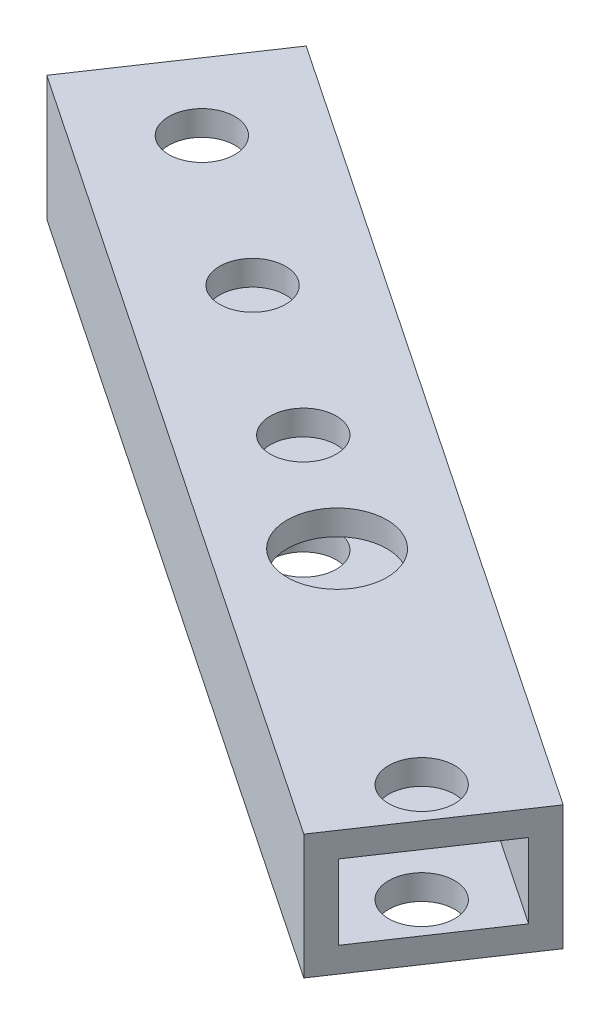
from build123d import *

# Parameters (mm, degrees)
SKETCH_1_R               = 275
SKETCH_1_R_2             = 255
EXTRUDE_1_DEPTH          = 10
EXTRUDE_2_DEPTH          = 10
SKETCH_8_R               = 2.65
SKETCH_8_R_2             = 1.65
SKETCH_8_R_3             = 2.15
CUT_EXTRUDE_1_DEPTH      = 21
SKETCH_9_OUTSIDE_W       = 707.614
SKETCH_9_OUTSIDE_H       = 707.614
CUT_EXTRUDE_2_DEPTH      = 21
EXTRUDE_3_DEPTH          = 10
SKETCH_11_W              = 11
SKETCH_11_H              = 6
CUT_EXTRUDE_3_DEPTH      = 509.636319812
CUT_EXTRUDE_3_DEPTH_BACK = 255.723154156
SKETCH_12_W              = 684.820669576
SKETCH_12_H              = 20
CUT_EXTRUDE_4_DEPTH      = 230.939436413
CUT_EXTRUDE_4_DEPTH_BACK = 534.420037555
SKETCH_14_R              = 4
CUT_EXTRUDE_6_DEPTH      = 11


with BuildPart() as part:
    # 草图1 → 凸台-拉伸1 (new body)
    with BuildSketch(Plane(origin=(0, 0, 0), x_dir=(1, 0, 0), z_dir=(0, 1, 0))):
        Circle(SKETCH_1_R)
        Circle(SKETCH_1_R_2, mode=Mode.SUBTRACT)
    extrude(amount=EXTRUDE_1_DEPTH)

    # 草图12 → 切除-拉伸4 (cut, two sides)
    with BuildSketch(Plane(origin=(84.710658728, 0, -125.893697679), x_dir=(-0.829665535, 0, -0.558260781), z_dir=(0.558260781, 0, -0.829665535))) as cut_extrude_4_sk:
        Rectangle(SKETCH_12_W, SKETCH_12_H)
    extrude(amount=CUT_EXTRUDE_4_DEPTH, mode=Mode.SUBTRACT)
    extrude(cut_extrude_4_sk.sketch, amount=-CUT_EXTRUDE_4_DEPTH_BACK, mode=Mode.SUBTRACT)


with BuildPart() as body_2:
    # 草图2 → 凸台-拉伸2 (new body)
    with BuildSketch(Plane(origin=(0, 10, 0), x_dir=(1, 0, 0), z_dir=(0, 1, 0))):
        with BuildLine():
            Line((-110.525139894, 257.262887824), (-25.423255477, 200))
            Line((-25.423255477, 200), (0, 200))
            Line((0, 200), (25.423255477, 200))
            Line((25.423255477, 200), (110.525139894, 257.262887824))
            ThreePointArc((110.525139894, 257.262887824), (197.989898732, 197.989898732), (257.262887824, 110.525139894))
            Line((257.262887824, 110.525139894), (200, 25.423255477))
            Line((200, 25.423255477), (200, 0))
            Line((200, 0), (200, -25.423255477))
            Line((200, -25.423255477), (257.262887824, -110.525139894))
            ThreePointArc((257.262887824, -110.525139894), (197.989898732, -197.989898732), (110.525139894, -257.262887824))
            Line((110.525139894, -257.262887824), (25.423255477, -200))
            Line((25.423255477, -200), (0, -200))
            Line((0, -200), (-25.423255477, -200))
            Line((-25.423255477, -200), (-110.525139894, -257.262887824))
            ThreePointArc((-110.525139894, -257.262887824), (-197.989898732, -197.989898732), (-257.262887824, -110.525139894))
            Line((-257.262887824, -110.525139894), (-200, -25.423255477))
            Line((-200, -25.423255477), (-200, 25.423255477))
            Line((-200, 25.423255477), (-257.262887824, 110.525139894))
            ThreePointArc((-257.262887824, 110.525139894), (-197.989898732, 197.989898732), (-110.525139894, 257.262887824))
        make_face()
        with BuildLine():
            Line((0, 185), (30, 185))
            Line((30, 185), (111.993839361, 240.171563565))
            ThreePointArc((111.993839361, 240.171563565), (187.383297014, 187.383297014), (240.171563565, 111.993839361))
            Line((240.171563565, 111.993839361), (185, 30))
            Line((185, 30), (185, 0))
            Line((185, 0), (185, -30))
            Line((185, -30), (240.171563565, -111.993839361))
            ThreePointArc((240.171563565, -111.993839361), (187.383297014, -187.383297014), (111.993839361, -240.171563565))
            Line((111.993839361, -240.171563565), (30, -185))
            Line((30, -185), (0, -185))
            Line((0, -185), (-30, -185))
            Line((-30, -185), (-111.993839361, -240.171563565))
            ThreePointArc((-111.993839361, -240.171563565), (-187.383297014, -187.383297014), (-240.171563565, -111.993839361))
            Line((-240.171563565, -111.993839361), (-185, -30))
            Line((-185, -30), (-185, 30))
            Line((-185, 30), (-240.171563565, 111.993839361))
            ThreePointArc((-240.171563565, 111.993839361), (-187.383297014, 187.383297014), (-111.993839361, 240.171563565))
            Line((-111.993839361, 240.171563565), (-30, 185))
            Line((-30, 185), (0, 185))
        make_face(mode=Mode.SUBTRACT)
    extrude(amount=EXTRUDE_2_DEPTH)

    # 草图8 → 切除-拉伸1 (cut, through all)
    with BuildSketch(Plane(origin=(0, 20, 0), x_dir=(1, 0, 0), z_dir=(0, 1, 0))):
        with Locations((-10, 192.5)):
            Circle(SKETCH_8_R)
        with Locations((10, 192.5)):
            Circle(SKETCH_8_R)
        with Locations((-10, -192.5)):
            Circle(SKETCH_8_R)
        with Locations((10, -192.5)):
            Circle(SKETCH_8_R)
        with Locations((192.5, 10)):
            Circle(SKETCH_8_R)
        with Locations((192.5, -10)):
            Circle(SKETCH_8_R)
        with Locations((-192.5, 10)):
            Circle(SKETCH_8_R)
        with Locations((-192.5, -10)):
            Circle(SKETCH_8_R)
        with Locations((-110.525139894, 248.223100485)):
            Circle(SKETCH_8_R_2)
        with Locations((-27.711627738, 192.5)):
            Circle(SKETCH_8_R)
        with Locations((-56.749921469, 212.03912734)):
            Circle(SKETCH_8_R)
        with Locations((-69.194904497, 220.413039057)):
            Circle(SKETCH_8_R)
        with Locations((-81.639887524, 228.786950774)):
            Circle(SKETCH_8_R)
        with Locations((-143.808163456, 231.45377032)):
            Circle(SKETCH_8_R_3)
        with Locations((-164.415519771, 217.299729706)):
            Circle(SKETCH_8_R_3)
        with Locations((-183.638937552, 201.316607082)):
            Circle(SKETCH_8_R_3)
        with Locations((-201.316607082, 183.638937552)):
            Circle(SKETCH_8_R_3)
        with Locations((-217.299729706, 164.415519771)):
            Circle(SKETCH_8_R_3)
        with Locations((-231.45377032, 143.808163456)):
            Circle(SKETCH_8_R_3)
        with Locations((-128.811575358, 240.123330241)):
            Circle(SKETCH_8_R)
        with Locations((-240.123330241, 128.811575358)):
            Circle(SKETCH_8_R)
        with Locations((-228.786950774, 81.639887524)):
            Circle(SKETCH_8_R)
        with Locations((-220.413039057, 69.194904497)):
            Circle(SKETCH_8_R)
        with Locations((-212.03912734, 56.749921469)):
            Circle(SKETCH_8_R)
        with Locations((-203.665215623, 44.304938442)):
            Circle(SKETCH_8_R)
        with Locations((-192.5, 27.711627738)):
            Circle(SKETCH_8_R)
        with Locations((-248.223100485, 110.525139894)):
            Circle(SKETCH_8_R_2)
        with Locations((192.5, 27.711627738)):
            Circle(SKETCH_8_R)
        with Locations((248.223100485, 110.525139894)):
            Circle(SKETCH_8_R_2)
        with Locations((203.665215623, 44.304938442)):
            Circle(SKETCH_8_R)
        with Locations((212.03912734, 56.749921469)):
            Circle(SKETCH_8_R)
        with Locations((220.413039057, 69.194904497)):
            Circle(SKETCH_8_R)
        with Locations((228.786950774, 81.639887524)):
            Circle(SKETCH_8_R)
        with Locations((240.123330241, 128.811575358)):
            Circle(SKETCH_8_R)
        with Locations((231.45377032, 143.808163456)):
            Circle(SKETCH_8_R_3)
        with Locations((128.811575358, 240.123330241)):
            Circle(SKETCH_8_R)
        with Locations((201.316607082, 183.638937552)):
            Circle(SKETCH_8_R_3)
        with Locations((183.638937552, 201.316607082)):
            Circle(SKETCH_8_R_3)
        with Locations((164.415519771, 217.299729706)):
            Circle(SKETCH_8_R_3)
        with Locations((143.808163456, 231.45377032)):
            Circle(SKETCH_8_R_3)
        with Locations((81.639887524, 228.786950774)):
            Circle(SKETCH_8_R)
        with Locations((69.194904497, 220.413039057)):
            Circle(SKETCH_8_R)
        with Locations((56.749921469, 212.03912734)):
            Circle(SKETCH_8_R)
        with Locations((110.525139894, 248.223100485)):
            Circle(SKETCH_8_R_2)
        with Locations((27.711627738, 192.5)):
            Circle(SKETCH_8_R)
        with Locations((217.299729706, 164.415519771)):
            Circle(SKETCH_8_R_3)
    extrude(amount=-CUT_EXTRUDE_1_DEPTH, mode=Mode.SUBTRACT)

    # 草图9 outside → 切除-拉伸2 (cut, through all)
    with BuildSketch(Plane(origin=(0, 20, 0), x_dir=(1, 0, 0), z_dir=(0, 1, 0))):
        Rectangle(SKETCH_9_OUTSIDE_W, SKETCH_9_OUTSIDE_H)
        Polygon((-28.994754224, 184.323595752), (-20.620842507, 196.76857878), (-83.675423179, 239.196398147), (-92.049334896, 226.751415119), align=None, mode=Mode.SUBTRACT)
    extrude(amount=-CUT_EXTRUDE_2_DEPTH, mode=Mode.SUBTRACT)

    # 草图10 → 凸台-拉伸3 (add)
    with BuildSketch(Plane(origin=(0, 20, 0), x_dir=(1, 0, 0), z_dir=(0, 1, 0))):
        Polygon((-28.539619055, 185), (-28.994754224, 184.323595752), (-30, 185), align=None)
    extrude(amount=-EXTRUDE_3_DEPTH)

    # 草图11 → 切除-拉伸3 (cut, two sides)
    with BuildSketch(Plane(origin=(-105.331501234, 0, -70.874881101), x_dir=(0.558260781, 0, -0.829665535), z_dir=(0.829665535, 0, 0.558260781))) as cut_extrude_3_sk:
        with Locations((144.240300571, 15)):
            Rectangle(SKETCH_11_W, SKETCH_11_H)
    extrude(amount=CUT_EXTRUDE_3_DEPTH, mode=Mode.SUBTRACT)
    extrude(cut_extrude_3_sk.sketch, amount=-CUT_EXTRUDE_3_DEPTH_BACK, mode=Mode.SUBTRACT)

    # 草图14 → 切除-拉伸6 (cut, through all)
    with BuildSketch(Plane.XZ.offset(-10)):
        with Locations((-47.5, -205.5)):
            Circle(SKETCH_14_R)
    extrude(amount=-CUT_EXTRUDE_6_DEPTH, mode=Mode.SUBTRACT)


solid = body_2.part
